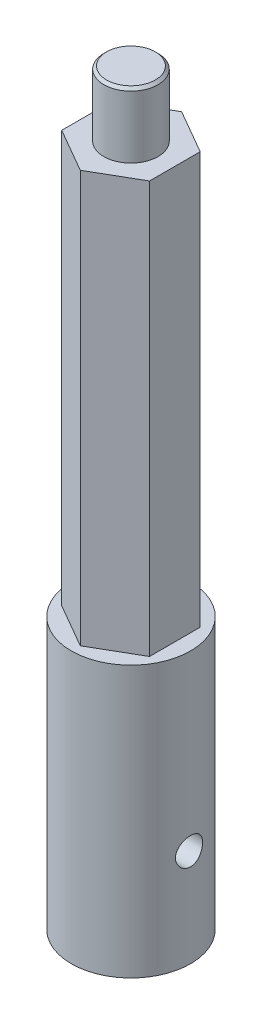
from build123d import *
from build123d.topology import SkipClean

# Parameters (mm, degrees)
SKETCH_1_R          = 5.5
EXTRUDE_1_DEPTH     = 25
EXTRUDE_2_DEPTH     = 38
SKETCH_3_R          = 2.5
EXTRUDE_4_DEPTH     = 6
CHAMFER_1_SIZE      = 0.25
CUT_EXTRUDE_1_DEPTH = 15
SKETCH_6_R          = 3
CUT_EXTRUDE_2_DEPTH = 3
M3X0_5_1_D          = 2.5
M3X0_5_1_DEPTH      = 3


with BuildPart() as part:
    # Sketch 1 → Extrude 1 (new body)
    with BuildSketch(Plane(origin=(0, 0, 0), x_dir=(1, 0, 0), z_dir=(0, 1, 0))):
        with Locations(Location((0, 0, 0), (0, 0, 270))):  # turned: the seam where the file's is
            Circle(SKETCH_1_R)
    extrude(amount=EXTRUDE_1_DEPTH)

    # Sketch 2 → Extrude 2 (add)
    with BuildSketch(Plane(origin=(0, 25, 0), x_dir=(1, 0, 0), z_dir=(0, 1, 0))):
        Polygon((0, -4.67653718), (4.05, -2.33826859), (4.05, 2.33826859), (0, 4.67653718), (-4.05, 2.33826859), (-4.05, -2.33826859), align=None)
    extrude(amount=EXTRUDE_2_DEPTH)

    # Sketch 3 → Extrude 4 (add)
    with BuildSketch(Plane(origin=(0, 63, 0), x_dir=(1, 0, 0), z_dir=(0, 1, 0))):
        with Locations(Location((0, 0, 0), (0, 0, 270))):  # turned: the seam where the file's is
            Circle(SKETCH_3_R)
    extrude(amount=EXTRUDE_4_DEPTH)

    # Chamfer 1
    chamfer_1_edges = [part.edges().sort_by_distance(p)[0] for p in [
        (0, 69, -2.5),
    ]]
    chamfer(chamfer_1_edges, length=CHAMFER_1_SIZE)

    # Sketch 5 → Cut-Extrude 1 (cut)
    with BuildSketch(Plane.XZ):
        with BuildLine():
            Line((2.5, 1.658312395), (2.5, -1.658312395))
            ThreePointArc((2.5, -1.658312395), (-3, 0), (2.5, 1.658312395))
        make_face()
    extrude(amount=-CUT_EXTRUDE_1_DEPTH, mode=Mode.SUBTRACT)

    # Sketch 6 → Cut-Extrude 2 (cut)
    with SkipClean():  # keep this step's faces unmerged: merging them makes the solid invalid here
        with BuildSketch(Plane.XZ):
            with Locations(Location((0, 0, 0), (0, 0, 270))):  # turned: the seam where the file's is
                Circle(SKETCH_6_R)
        extrude(amount=-CUT_EXTRUDE_2_DEPTH, mode=Mode.SUBTRACT)

    # M3x0.5 _1
    with Locations(Plane.ZY.offset(-2.5)):
        with Locations((0, 9)):
            Hole(M3X0_5_1_D / 2, depth=M3X0_5_1_DEPTH)


solid = part.part
